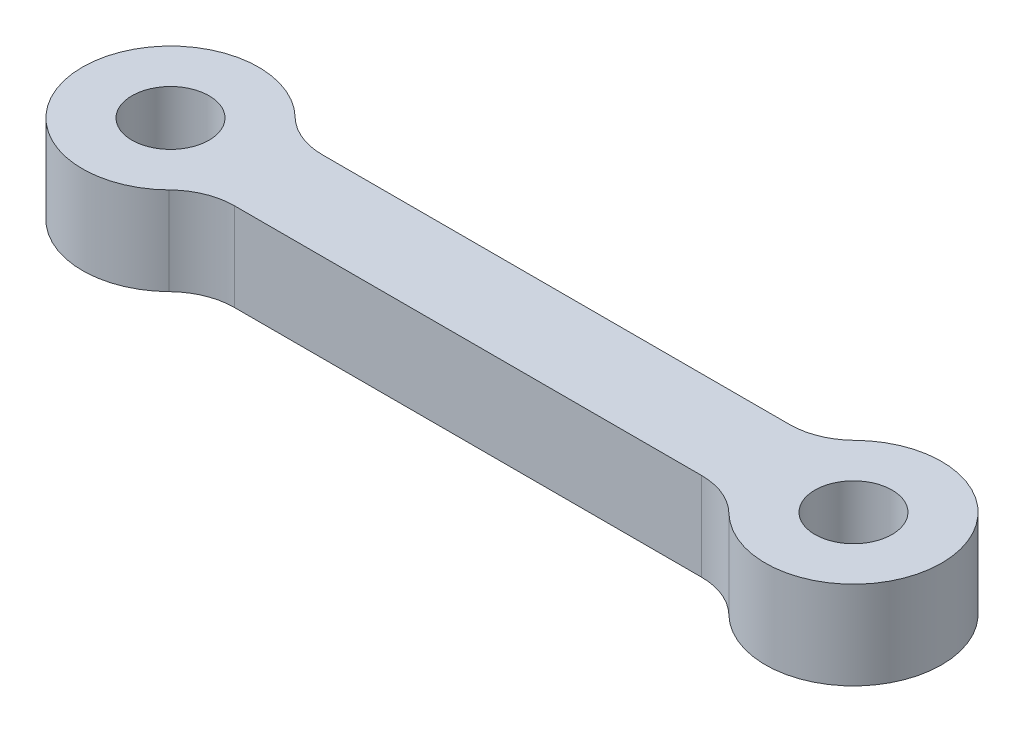
from build123d import *

# Parameters (mm, degrees)
SKETCH1_R           = 1.75
BOSS_EXTRUDE1_DEPTH = 4
FILLET1_R           = 3


with BuildPart() as part:
    # Sketch1 → Boss-Extrude1 (new body)
    with BuildSketch(Plane(origin=(0, 0, 0), x_dir=(1, 0, 0), z_dir=(0, 1, 0))):
        with BuildLine():
            Line((27.535898385, 2), (3.464101615, 2))
            ThreePointArc((3.464101615, 2), (-4, 0), (3.464101615, -2))
            Line((3.464101615, -2), (27.535898385, -2))
            ThreePointArc((27.535898385, -2), (35, 0), (27.535898385, 2))
        make_face()
        Circle(SKETCH1_R, mode=Mode.SUBTRACT)
        with Locations((31, 0)):
            Circle(SKETCH1_R, mode=Mode.SUBTRACT)
    extrude(amount=BOSS_EXTRUDE1_DEPTH)

    # Fillet1
    fillet1_edges = [part.edges().sort_by_distance(p)[0] for p in [
        (27.535898385, 2, 2),
        (3.464101615, 2, 2),
        (3.464101615, 2, -2),
        (27.535898385, 2, -2),
    ]]
    fillet(fillet1_edges, radius=FILLET1_R)


solid = part.part
